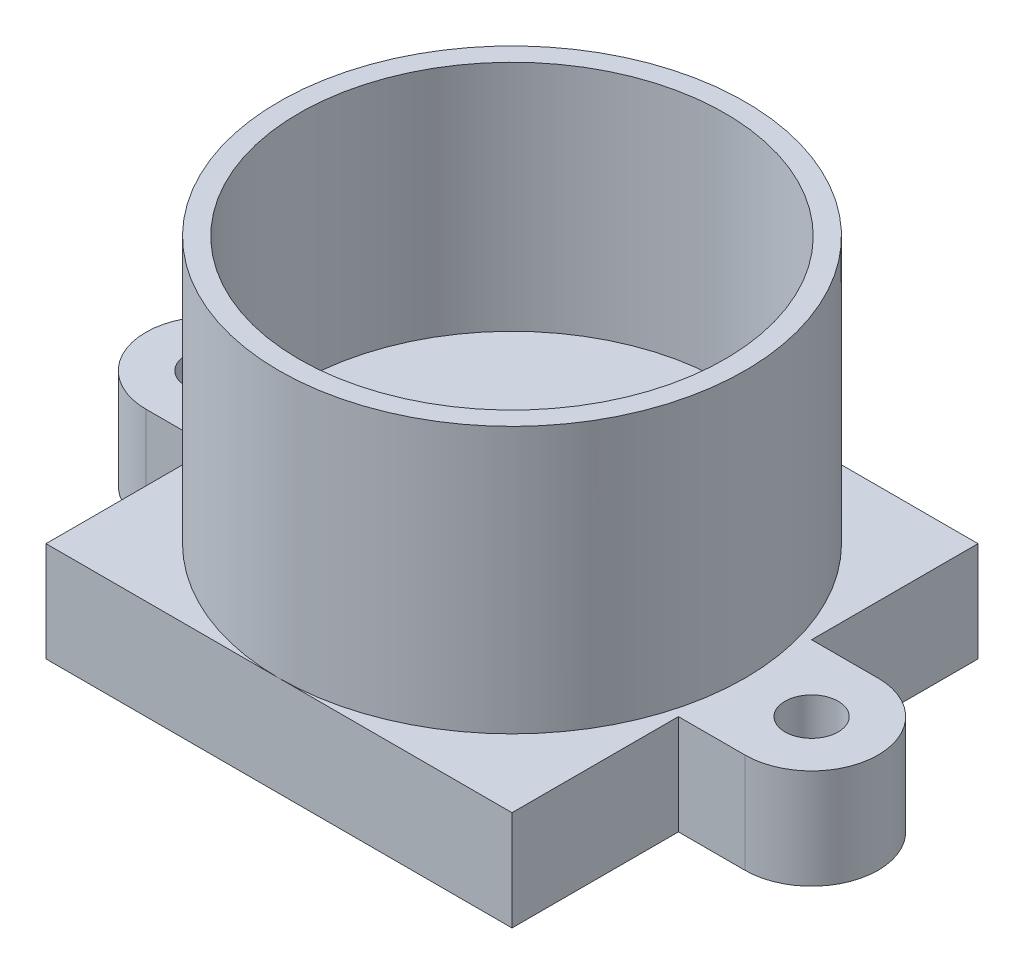
from build123d import *

# Parameters (mm, degrees)
SKETCH_1_W          = 14
SKETCH_1_H          = 14
EXTRUDE_2_DEPTH     = 3
EXTRUDE_4_DEPTH     = 3
EXTRUDE_5_DEPTH     = 3
SKETCH_4_R          = 0.8
CUT_EXTRUDE_1_DEPTH = 3
SKETCH_5_R          = 7
EXTRUDE_6_DEPTH     = 8
SKETCH_6_R          = 6.4
CUT_EXTRUDE_2_DEPTH = 7


with BuildPart() as part:
    # 草图1 → 凸台-拉伸2 (new body)
    with BuildSketch(Plane(origin=(0, 0, 0), x_dir=(1, 0, 0), z_dir=(0, 1, 0))):
        Rectangle(SKETCH_1_W, SKETCH_1_H)
    extrude(amount=EXTRUDE_2_DEPTH)

    # 草图2 → 凸台-拉伸4 (add)
    with BuildSketch(Plane(origin=(0, 3, 0), x_dir=(1, 0, 0), z_dir=(0, 1, 0))):
        Polygon((-7, 0), (-7, 2), (-9, 2), (-9, 0), (-9, -2), (-7, -2), align=None)
        Polygon((7, 0), (7, 2), (9, 2), (9, 0), (9, -2), (7, -2), align=None)
    extrude(amount=-EXTRUDE_4_DEPTH)

    # 草图3 → 凸台-拉伸5 (add)
    with BuildSketch(Plane(origin=(0, 3, 0), x_dir=(1, 0, 0), z_dir=(0, 1, 0))):
        with BuildLine():
            Line((-9, 2), (-9, -2))
            ThreePointArc((-9, -2), (-11, 0), (-9, 2))
        make_face()
        with BuildLine():
            Line((9, 2), (9, -2))
            ThreePointArc((9, -2), (11, 0), (9, 2))
        make_face()
    extrude(amount=-EXTRUDE_5_DEPTH)

    # 草图4 → 切除-拉伸1 (cut)
    with BuildSketch(Plane(origin=(0, 3, 0), x_dir=(1, 0, 0), z_dir=(0, 1, 0))):
        with Locations((-9, 0)):
            Circle(SKETCH_4_R)
        with Locations((9, 0)):
            Circle(SKETCH_4_R)
    extrude(amount=-CUT_EXTRUDE_1_DEPTH, mode=Mode.SUBTRACT)

    # 草图5 → 凸台-拉伸6 (add)
    with BuildSketch(Plane(origin=(0, 3, 0), x_dir=(1, 0, 0), z_dir=(0, 1, 0))):
        Circle(SKETCH_5_R)
    extrude(amount=EXTRUDE_6_DEPTH)

    # 草图6 → 切除-拉伸2 (cut)
    with BuildSketch(Plane(origin=(0, 11, 0), x_dir=(1, 0, 0), z_dir=(0, 1, 0))):
        Circle(SKETCH_6_R)
    extrude(amount=-CUT_EXTRUDE_2_DEPTH, mode=Mode.SUBTRACT)


solid = part.part
